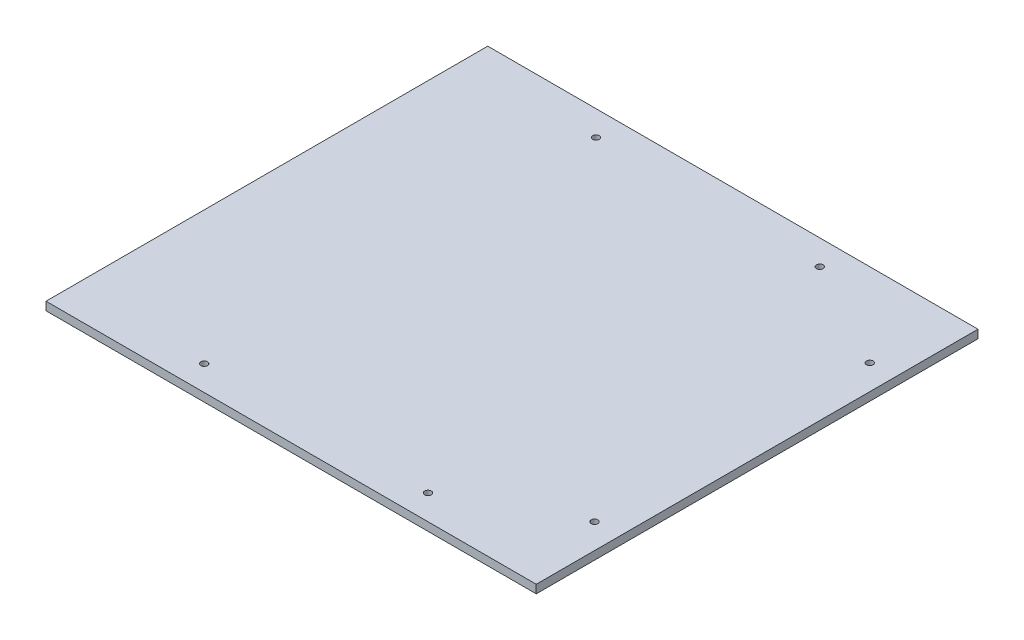
from build123d import *

# Parameters (mm, degrees)
SKETCH1_W           = 294.4
SKETCH1_H           = 265.28
BOSS_EXTRUDE1_DEPTH = 5
SKETCH2_R           = 2
CUT_EXTRUDE1_DEPTH  = 5
SKETCH3_R           = 2
CUT_EXTRUDE2_DEPTH  = 5


with BuildPart() as part:
    # Sketch1 → Boss-Extrude1 (new body)
    with BuildSketch(Plane(origin=(0, 0, 0), x_dir=(1, 0, 0), z_dir=(0, 1, 0))):
        Rectangle(SKETCH1_W, SKETCH1_H)
    extrude(amount=BOSS_EXTRUDE1_DEPTH)

    # Sketch2 → Cut-Extrude1 (cut)
    with BuildSketch(Plane(origin=(0, 5, 0), x_dir=(1, 0, 0), z_dir=(0, 1, 0))):
        with Locations((132.2, -82.64)):
            Circle(SKETCH2_R)
        with Locations((132.2, 82.64)):
            Circle(SKETCH2_R)
    extrude(amount=-CUT_EXTRUDE1_DEPTH, mode=Mode.SUBTRACT)

    # Sketch3 → Cut-Extrude2 (cut)
    with BuildSketch(Plane(origin=(0, 5, 0), x_dir=(1, 0, 0), z_dir=(0, 1, 0))):
        with Locations((-67.2, 117.64)):
            Circle(SKETCH3_R)
        with Locations((67.2, 117.64)):
            Circle(SKETCH3_R)
        with Locations((67.2, -117.64)):
            Circle(SKETCH3_R)
        with Locations((-67.2, -117.64)):
            Circle(SKETCH3_R)
    extrude(amount=-CUT_EXTRUDE2_DEPTH, mode=Mode.SUBTRACT)


solid = part.part
